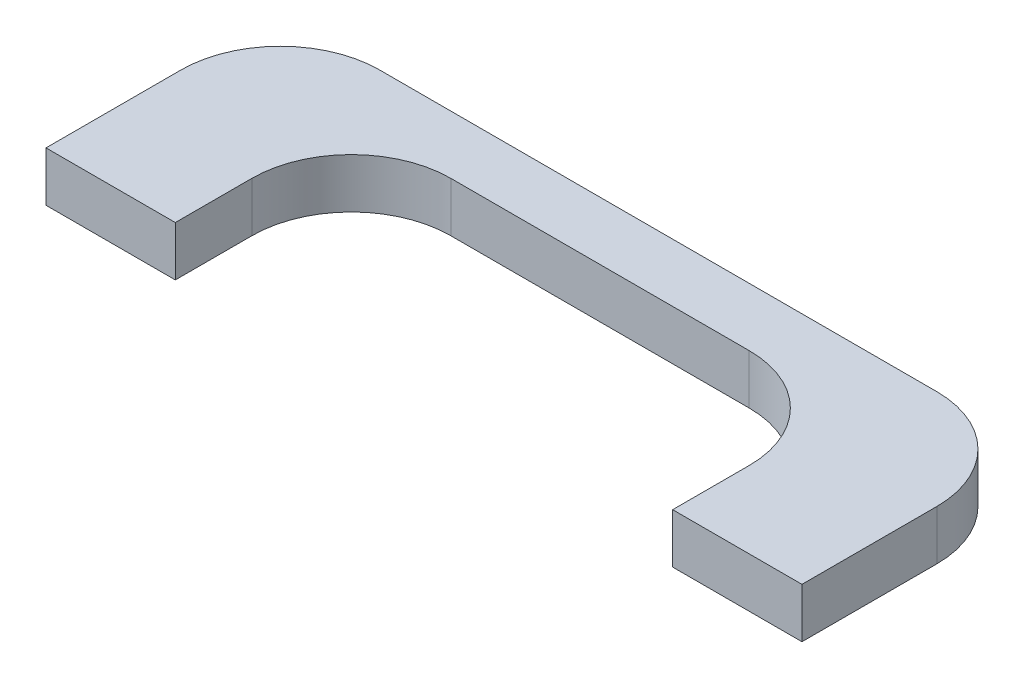
from build123d import *

# Parameters (mm, degrees)
SALIENTE_EXTRUIR2_DEPTH = 5


with BuildPart() as part:
    # Croquis1 → Saliente-Extruir2 (new body)
    with BuildSketch(Plane(origin=(0, 0, 0), x_dir=(1, 0, 0), z_dir=(0, 1, 0))):
        with BuildLine():
            Line((0, 0), (13, 0))
            Line((13, 0), (13, 7.6962052))
            ThreePointArc((13, 7.6962052), (15.928932188, 14.767273012), (23, 17.6962052))
            Line((23, 17.6962052), (53, 17.6962052))
            ThreePointArc((53, 17.6962052), (60.071067812, 14.767273012), (63, 7.6962052))
            Line((63, 7.6962052), (63, 0))
            Line((63, 0), (76, 0))
            Line((76, 0), (76, 13.554999328))
            ThreePointArc((76, 13.554999328), (73.071067812, 20.62606714), (66, 23.554999328))
            Line((66, 23.554999328), (10, 23.554999328))
            ThreePointArc((10, 23.554999328), (2.928932188, 20.62606714), (0, 13.554999328))
            Line((0, 13.554999328), (0, 0))
        make_face()
    extrude(amount=SALIENTE_EXTRUIR2_DEPTH)


solid = part.part
